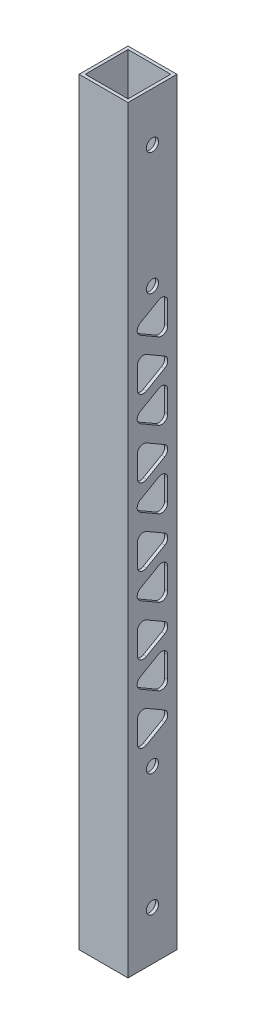
from build123d import *

# Parameters (mm, degrees)
SKETCH1_W           = 50.8
SKETCH1_H           = 50.8
SKETCH1_W_2         = 44.416753927
SKETCH1_H_2         = 44.416753927
BOSS_EXTRUDE1_DEPTH = 787.4
SKETCH2_R           = 6.35
CUT_EXTRUDE1_DEPTH  = 51.8
CUT_EXTRUDE2_DEPTH  = 76.2


with BuildPart() as part:
    # Sketch1 → Boss-Extrude1 (new body)
    with BuildSketch(Plane(origin=(0, 0, 0), x_dir=(1, 0, 0), z_dir=(0, 1, 0))):
        Rectangle(SKETCH1_W, SKETCH1_H)
        with Locations((-0.016623037, 0.016623037)):
            Rectangle(SKETCH1_W_2, SKETCH1_H_2, mode=Mode.SUBTRACT)
    extrude(amount=BOSS_EXTRUDE1_DEPTH)

    # Sketch2 → Cut-Extrude1 (cut, through all)
    with BuildSketch(Plane.ZY.offset(25.4)):
        with Locations((0, 50.8)):
            Circle(SKETCH2_R)
        with Locations((0, 177.8)):
            Circle(SKETCH2_R)
        with Locations((0, 609.6)):
            Circle(SKETCH2_R)
        with Locations((0, 736.6)):
            Circle(SKETCH2_R)
    extrude(amount=-CUT_EXTRUDE1_DEPTH, mode=Mode.SUBTRACT)

    # Sketch3 → Cut-Extrude2 (cut)
    with BuildSketch(Plane.ZY.offset(25.4)):
        with BuildLine():
            Line((-12.7, 210.943226022), (6.210922198, 200.025))
            ThreePointArc((6.210922198, 200.025), (12.560922198, 200.025), (15.735922198, 205.524261314))
            Line((15.735922198, 205.524261314), (15.735922198, 227.360713358))
            ThreePointArc((15.735922198, 227.360713358), (12.560922198, 232.859974672), (6.210922198, 232.859974672))
            Line((6.210922198, 232.859974672), (-12.7, 221.94174865))
            ThreePointArc((-12.7, 221.94174865), (-15.875, 216.442487336), (-12.7, 210.943226022))
        make_face()
        with BuildLine():
            Line((12.7, 264.382019928), (-6.35, 275.380542556))
            ThreePointArc((-6.35, 275.380542556), (-12.7, 275.380542556), (-15.875, 269.881281242))
            Line((-15.875, 269.881281242), (-15.875, 247.884235986))
            ThreePointArc((-15.875, 247.884235986), (-12.7, 242.384974672), (-6.35, 242.384974672))
            Line((-6.35, 242.384974672), (12.7, 253.3834973))
            ThreePointArc((12.7, 253.3834973), (15.875, 258.882758614), (12.7, 264.382019928))
        make_face()
        with BuildLine():
            Line((-12.7, 290.529340383), (6.210922198, 279.611114361))
            ThreePointArc((6.210922198, 279.611114361), (12.560922198, 279.611114361), (15.735922198, 285.110375675))
            Line((15.735922198, 285.110375675), (15.735922198, 306.946827719))
            ThreePointArc((15.735922198, 306.946827719), (12.560922198, 312.446089033), (6.210922198, 312.446089033))
            Line((6.210922198, 312.446089033), (-12.7, 301.527863011))
            ThreePointArc((-12.7, 301.527863011), (-15.875, 296.028601697), (-12.7, 290.529340383))
        make_face()
        with BuildLine():
            Line((12.7, 343.968134289), (-6.35, 354.966656917))
            ThreePointArc((-6.35, 354.966656917), (-12.7, 354.966656917), (-15.875, 349.467395603))
            Line((-15.875, 349.467395603), (-15.875, 327.470350347))
            ThreePointArc((-15.875, 327.470350347), (-12.7, 321.971089033), (-6.35, 321.971089033))
            Line((-6.35, 321.971089033), (12.7, 332.969611661))
            ThreePointArc((12.7, 332.969611661), (15.875, 338.468872975), (12.7, 343.968134289))
        make_face()
        with BuildLine():
            Line((-12.7, 370.115454744), (6.210922198, 359.197228722))
            ThreePointArc((6.210922198, 359.197228722), (12.560922198, 359.197228722), (15.735922198, 364.696490036))
            Line((15.735922198, 364.696490036), (15.735922198, 386.53294208))
            ThreePointArc((15.735922198, 386.53294208), (12.560922198, 392.032203394), (6.210922198, 392.032203394))
            Line((6.210922198, 392.032203394), (-12.7, 381.113977372))
            ThreePointArc((-12.7, 381.113977372), (-15.875, 375.614716058), (-12.7, 370.115454744))
        make_face()
        with BuildLine():
            Line((12.7, 423.55424865), (-6.35, 434.552771278))
            ThreePointArc((-6.35, 434.552771278), (-12.7, 434.552771278), (-15.875, 429.053509964))
            Line((-15.875, 429.053509964), (-15.875, 407.056464708))
            ThreePointArc((-15.875, 407.056464708), (-12.7, 401.557203394), (-6.35, 401.557203394))
            Line((-6.35, 401.557203394), (12.7, 412.555726022))
            ThreePointArc((12.7, 412.555726022), (15.875, 418.054987336), (12.7, 423.55424865))
        make_face()
        with BuildLine():
            Line((-12.7, 449.701569105), (6.210922198, 438.783343083))
            ThreePointArc((6.210922198, 438.783343083), (12.560922198, 438.783343083), (15.735922198, 444.282604397))
            Line((15.735922198, 444.282604397), (15.735922198, 466.119056441))
            ThreePointArc((15.735922198, 466.119056441), (12.560922198, 471.618317755), (6.210922198, 471.618317755))
            Line((6.210922198, 471.618317755), (-12.7, 460.700091733))
            ThreePointArc((-12.7, 460.700091733), (-15.875, 455.200830419), (-12.7, 449.701569105))
        make_face()
        with BuildLine():
            Line((12.7, 503.140363011), (-6.35, 514.138885639))
            ThreePointArc((-6.35, 514.138885639), (-12.7, 514.138885639), (-15.875, 508.639624325))
            Line((-15.875, 508.639624325), (-15.875, 486.642579069))
            ThreePointArc((-15.875, 486.642579069), (-12.7, 481.143317755), (-6.35, 481.143317755))
            Line((-6.35, 481.143317755), (12.7, 492.141840383))
            ThreePointArc((12.7, 492.141840383), (15.875, 497.641101697), (12.7, 503.140363011))
        make_face()
        with BuildLine():
            Line((-12.7, 529.287683466), (6.210922198, 518.369457444))
            ThreePointArc((6.210922198, 518.369457444), (12.560922198, 518.369457444), (15.735922198, 523.868718758))
            Line((15.735922198, 523.868718758), (15.735922198, 545.705170802))
            ThreePointArc((15.735922198, 545.705170802), (12.560922198, 551.204432116), (6.210922198, 551.204432116))
            Line((6.210922198, 551.204432116), (-12.7, 540.286206094))
            ThreePointArc((-12.7, 540.286206094), (-15.875, 534.78694478), (-12.7, 529.287683466))
        make_face()
        with BuildLine():
            Line((12.7, 582.726477372), (-6.35, 593.725))
            ThreePointArc((-6.35, 593.725), (-12.7, 593.725), (-15.875, 588.225738686))
            Line((-15.875, 588.225738686), (-15.875, 566.22869343))
            ThreePointArc((-15.875, 566.22869343), (-12.7, 560.729432116), (-6.35, 560.729432116))
            Line((-6.35, 560.729432116), (12.7, 571.727954744))
            ThreePointArc((12.7, 571.727954744), (15.875, 577.227216058), (12.7, 582.726477372))
        make_face()
    extrude(amount=-CUT_EXTRUDE2_DEPTH, mode=Mode.SUBTRACT)


solid = part.part
